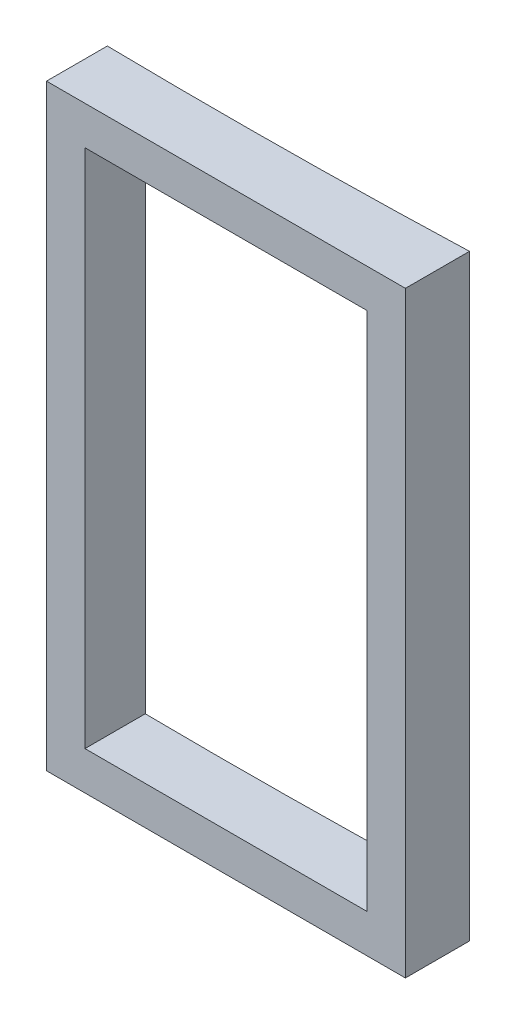
from build123d import *

# Parameters (mm, degrees)
BOSS_EXTRUDE1_DEPTH = 2330
SKETCH3_W           = 1100
SKETCH3_H           = 2030
CUT_EXTRUDE1_DEPTH  = 3000


with BuildPart() as part:
    # Sketch2 → Boss-Extrude1 (new body)
    with BuildSketch(Plane(origin=(0, 0, 0), x_dir=(1, 0, 0), z_dir=(0, 1, 0))):
        with BuildLine():
            Line((-6692.186143144, -5017.367964626), (-6692.186143144, -5267.367964626))
            Line((-6692.186143144, -5267.367964626), (-8092.186143144, -5267.367964626))
            Line((-8092.186143144, -5267.367964626), (-8092.186143144, -5030.09988938))
            ThreePointArc((-8092.186143144, -5030.09988938), (-7392.105105324, -5032.64483009), (-6692.186143144, -5017.367964626))
        make_face()
    extrude(amount=BOSS_EXTRUDE1_DEPTH)

    # Sketch3 → Cut-Extrude1 (cut)
    with BuildSketch(Plane.XY.offset(5267.367964626)):
        with Locations((-7392.186143144, 1165)):
            Rectangle(SKETCH3_W, SKETCH3_H)
    extrude(amount=-CUT_EXTRUDE1_DEPTH, mode=Mode.SUBTRACT)


solid = part.part
